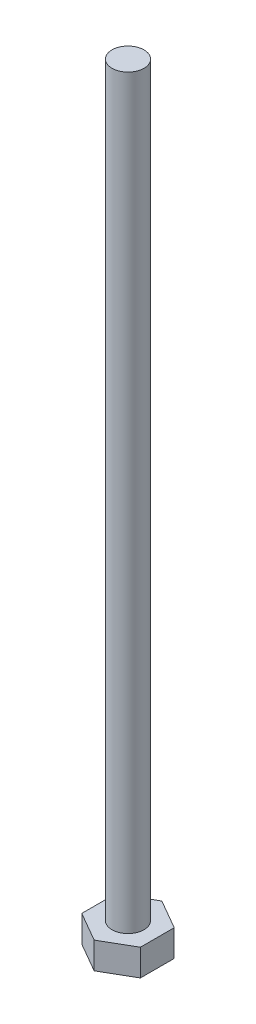
from build123d import *

# Parameters (mm, degrees)
BOSS_EXTRUDE1_DEPTH = 2.5
SKETCH2_R           = 1.5
BOSS_EXTRUDE2_DEPTH = 70


with BuildPart() as part:
    # Sketch1 → Boss-Extrude1 (new body)
    with BuildSketch(Plane(origin=(0, 0, 0), x_dir=(1, 0, 0), z_dir=(0, 1, 0))):
        Polygon((2.75, 1.58771324), (0, 3.175426481), (-2.75, 1.58771324), (-2.75, -1.58771324), (0, -3.175426481), (2.75, -1.58771324), align=None)
    extrude(amount=BOSS_EXTRUDE1_DEPTH)

    # Sketch2 → Boss-Extrude2 (add)
    with BuildSketch(Plane(origin=(0, 2.5, 0), x_dir=(1, 0, 0), z_dir=(0, 1, 0))):
        Circle(SKETCH2_R)
    extrude(amount=BOSS_EXTRUDE2_DEPTH)


solid = part.part
